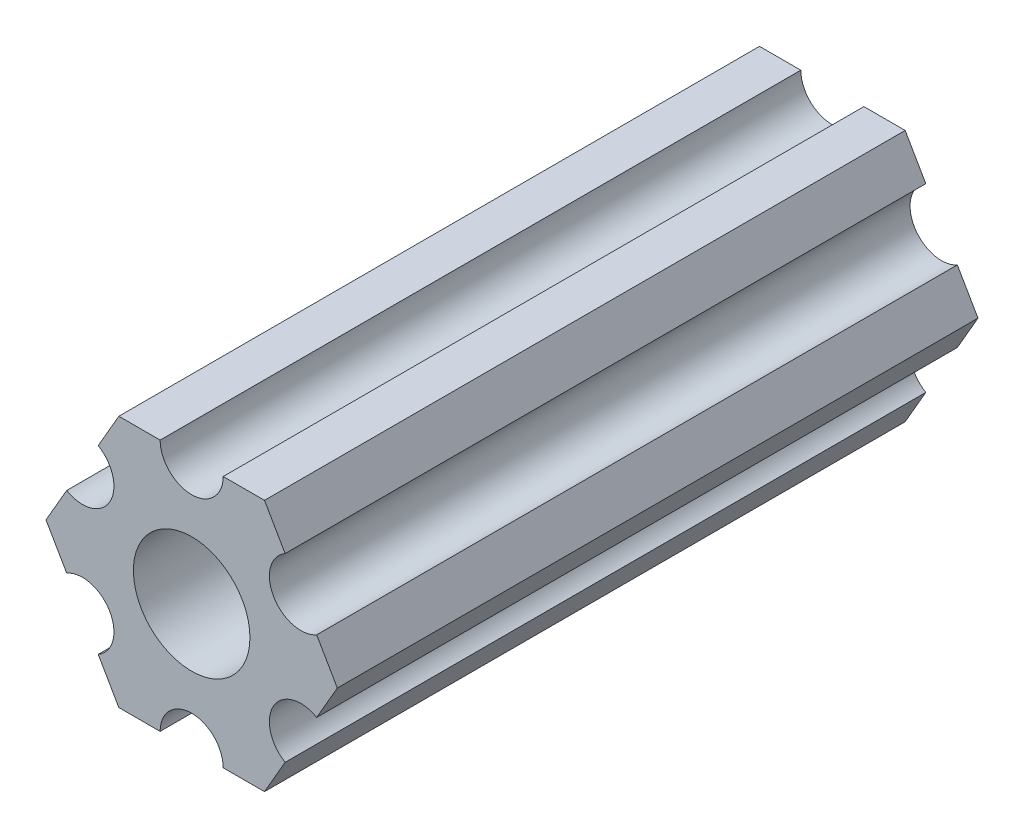
from build123d import *

# Parameters (mm, degrees)
SKETCH1_R           = 2.9337
BOSS_EXTRUDE1_DEPTH = 32.249999


with BuildPart() as part:
    # Sketch1 → Boss-Extrude1 (new body)
    with BuildSketch(Plane(origin=(0, 0, 0), x_dir=(-1, 0, 0), z_dir=(0, 0, -1))):
        with BuildLine():
            Line((-4.70551159, -4.549815043), (-3.666174521, -6.349999904))
            Line((-3.666174521, -6.349999904), (-1.587500385, -6.349999904))
            ThreePointArc((-1.587500385, -6.349999904), (-3.85e-07, -4.762499904), (1.587499615, -6.349999904))
            Line((1.587499615, -6.349999904), (3.666173825, -6.349999904))
            Line((3.666173825, -6.349999904), (4.705510942, -4.54981524))
            ThreePointArc((4.705510942, -4.54981524), (4.124445629, -2.381249907), (6.293010962, -1.800184594))
            Line((6.293010962, -1.800184594), (7.332348079, 7e-08))
            Line((7.332348079, 7e-08), (6.293011217, 1.800184685))
            ThreePointArc((6.293011217, 1.800184685), (4.124445939, 2.381250203), (4.705511457, 4.549815481))
            Line((4.705511457, 4.549815481), (3.666174521, 6.350000222))
            Line((3.666174521, 6.350000222), (1.587500385, 6.350000222))
            ThreePointArc((1.587500385, 6.350000222), (3.85e-07, 4.762500222), (-1.587499615, 6.350000222))
            Line((-1.587499615, 6.350000222), (-3.666173825, 6.350000222))
            Line((-3.666173825, 6.350000222), (-4.705511038, 4.549815614))
            ThreePointArc((-4.705511038, 4.549815614), (-4.124445841, 2.38125025), (-6.293011205, 1.800185053))
            Line((-6.293011205, 1.800185053), (-7.332348419, 4.44e-07))
            Line((-7.332348419, 4.44e-07), (-6.293011423, -1.80018429))
            ThreePointArc((-6.293011423, -1.80018429), (-4.12444613, -2.38124975), (-4.70551159, -4.549815043))
        make_face()
        Circle(SKETCH1_R, mode=Mode.SUBTRACT)
    extrude(amount=-BOSS_EXTRUDE1_DEPTH)


solid = part.part
